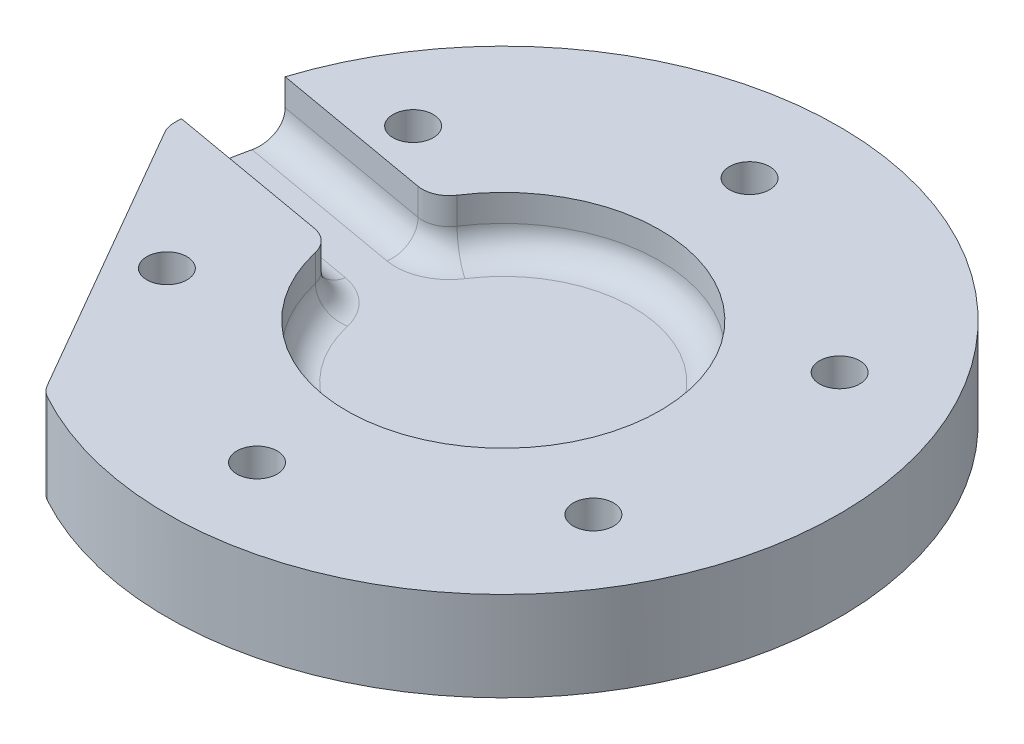
from build123d import *

# Parameters (mm, degrees)
SKETCH1_R           = 37.5
SKETCH1_R_2         = 2.25
BOSS_EXTRUDE1_DEPTH = 10
SKETCH4_R           = 17.5
CUT_EXTRUDE3_DEPTH  = 6
CUT_EXTRUDE1_DEPTH  = 6
CUT_EXTRUDE2_DEPTH  = 10
FILLET1_R           = 3


with BuildPart() as part:
    # Sketch1 → Boss-Extrude1 (new body)
    with BuildSketch(Plane(origin=(0, 0, 0), x_dir=(1, 0, 0), z_dir=(0, 1, 0))):
        Circle(SKETCH1_R)
        with Locations((0, 27.5)):
            Circle(SKETCH1_R_2, mode=Mode.SUBTRACT)
        with Locations((23.815698604, 13.75)):
            Circle(SKETCH1_R_2, mode=Mode.SUBTRACT)
        with Locations((23.815698604, -13.75)):
            Circle(SKETCH1_R_2, mode=Mode.SUBTRACT)
        with Locations((0, -27.5)):
            Circle(SKETCH1_R_2, mode=Mode.SUBTRACT)
        with Locations((-23.815698604, -13.75)):
            Circle(SKETCH1_R_2, mode=Mode.SUBTRACT)
        with Locations((-23.815698604, 13.75)):
            Circle(SKETCH1_R_2, mode=Mode.SUBTRACT)
    extrude(amount=BOSS_EXTRUDE1_DEPTH)

    # Sketch4 → Cut-Extrude3 (cut)
    with BuildSketch(Plane(origin=(0, 10, 0), x_dir=(1, 0, 0), z_dir=(0, 1, 0))):
        Circle(SKETCH4_R)
    extrude(amount=-CUT_EXTRUDE3_DEPTH, mode=Mode.SUBTRACT)

    # Sketch2 → Cut-Extrude1 (cut)
    with BuildSketch(Plane(origin=(0, 10, 0), x_dir=(1, 0, 0), z_dir=(0, 1, 0))):
        with BuildLine():
            Line((-37.468790286, 1.529625603), (-17.383968992, -2.011870294))
            ThreePointArc((-17.383968992, -2.011870294), (-17.234135678, 3.038843109), (-15.647487215, 7.836207236))
            Line((-15.647487215, 7.836207236), (-35.73230851, 11.377703133))
            ThreePointArc((-35.73230851, 11.377703133), (-36.930290738, 6.511806663), (-37.468790286, 1.529625603))
        make_face()
    extrude(amount=-CUT_EXTRUDE1_DEPTH, mode=Mode.SUBTRACT)

    # Sketch3 → Cut-Extrude2 (cut)
    with BuildSketch(Plane.XZ):
        with BuildLine():
            Line((-37.5, 0), (-18.75, 32.475952642))
            ThreePointArc((-18.75, 32.475952642), (-32.475952642, 18.75), (-37.5, 0))
        make_face()
    extrude(amount=-CUT_EXTRUDE2_DEPTH, mode=Mode.SUBTRACT)

    # Fillet1
    fillet1_edges = [part.edges().sort_by_distance(p)[0] for p in [
        (17.234135678, 4, 3.038843109),
        (-27.426379639, 4, 0.241122346),
        (-15.647487215, 7, -7.836207236),
        (-25.689897863, 4, -9.606955184),
        (-17.383968992, 7, 2.011870294),
        (-18.75, 5, 32.475952642),
        (-37.5, 5, 0),
    ]]
    fillet(fillet1_edges, radius=FILLET1_R)


solid = part.part
